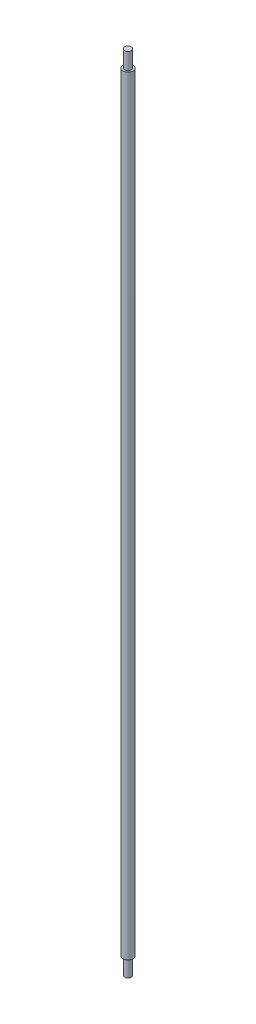
from build123d import *

# Parameters (mm, degrees)
SKETCH1_R           = 7.5
BOSS_EXTRUDE1_DEPTH = 1200
SKETCH2_OUTSIDE_W   = 257.038
SKETCH2_OUTSIDE_H   = 257.038
SKETCH2_OUTSIDE_R   = 5
CUT_EXTRUDE1_DEPTH  = 25
SKETCH3_OUTSIDE_W   = 257.038
SKETCH3_OUTSIDE_H   = 257.038
SKETCH3_OUTSIDE_R   = 5
CUT_EXTRUDE2_DEPTH  = 25


with BuildPart() as part:
    # Sketch1 → Boss-Extrude1 (new body)
    with BuildSketch(Plane(origin=(0, 0, 0), x_dir=(1, 0, 0), z_dir=(0, 1, 0))):
        Circle(SKETCH1_R)
    extrude(amount=BOSS_EXTRUDE1_DEPTH)

    # Sketch2 outside → Cut-Extrude1 (cut)
    with BuildSketch(Plane(origin=(0, 1200, 0), x_dir=(1, 0, 0), z_dir=(0, 1, 0))):
        Rectangle(SKETCH2_OUTSIDE_W, SKETCH2_OUTSIDE_H)
        Circle(SKETCH2_OUTSIDE_R, mode=Mode.SUBTRACT)
    extrude(amount=-CUT_EXTRUDE1_DEPTH, mode=Mode.SUBTRACT)

    # Sketch3 outside → Cut-Extrude2 (cut)
    with BuildSketch(Plane.XZ):
        Rectangle(SKETCH3_OUTSIDE_W, SKETCH3_OUTSIDE_H)
        Circle(SKETCH3_OUTSIDE_R, mode=Mode.SUBTRACT)
    extrude(amount=-CUT_EXTRUDE2_DEPTH, mode=Mode.SUBTRACT)


solid = part.part
